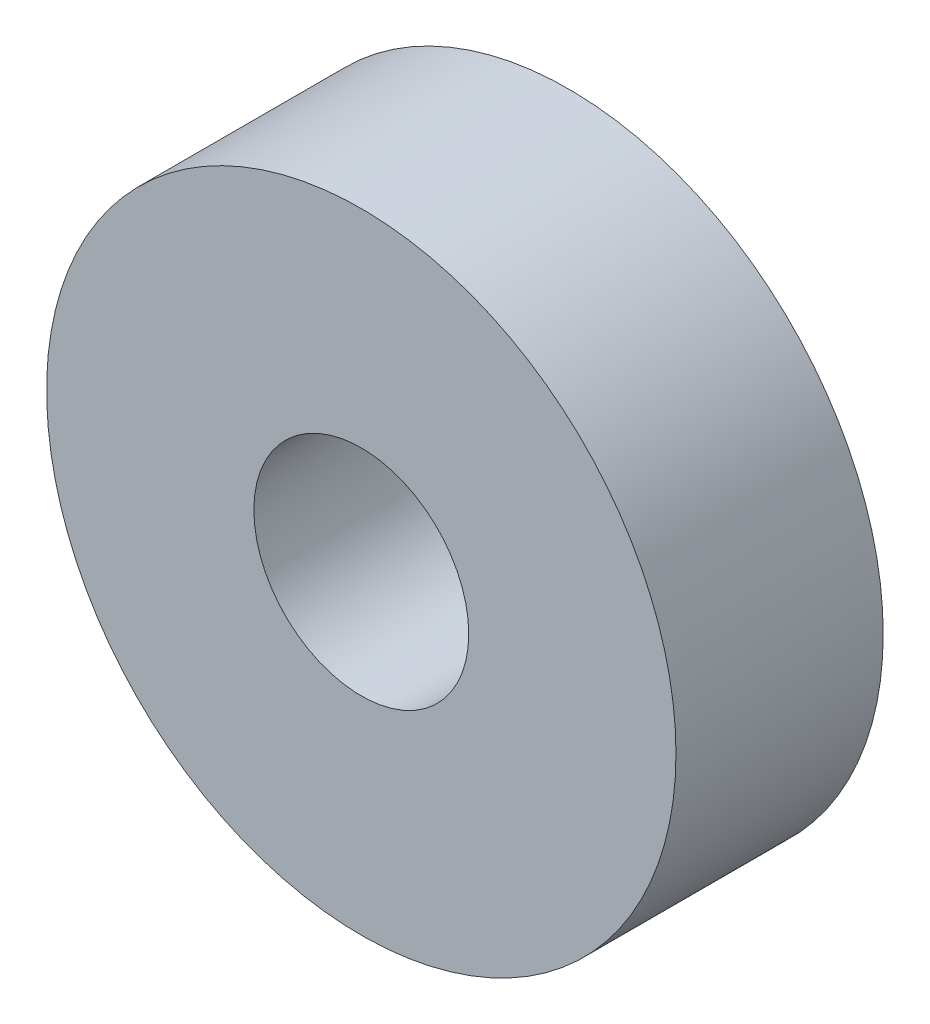
from build123d import *

# Parameters (mm, degrees)
SKETCH2_R           = 41
BOSS_EXTRUDE1_DEPTH = 27
SKETCH3_R           = 14
CUT_EXTRUDE1_DEPTH  = 27


with BuildPart() as part:
    # Sketch2 → Boss-Extrude1 (new body)
    with BuildSketch(Plane.XY):
        Circle(SKETCH2_R)
    extrude(amount=-BOSS_EXTRUDE1_DEPTH)

    # Sketch3 → Cut-Extrude1 (cut)
    with BuildSketch(Plane.XY):
        Circle(SKETCH3_R)
    extrude(amount=-CUT_EXTRUDE1_DEPTH, mode=Mode.SUBTRACT)


solid = part.part
